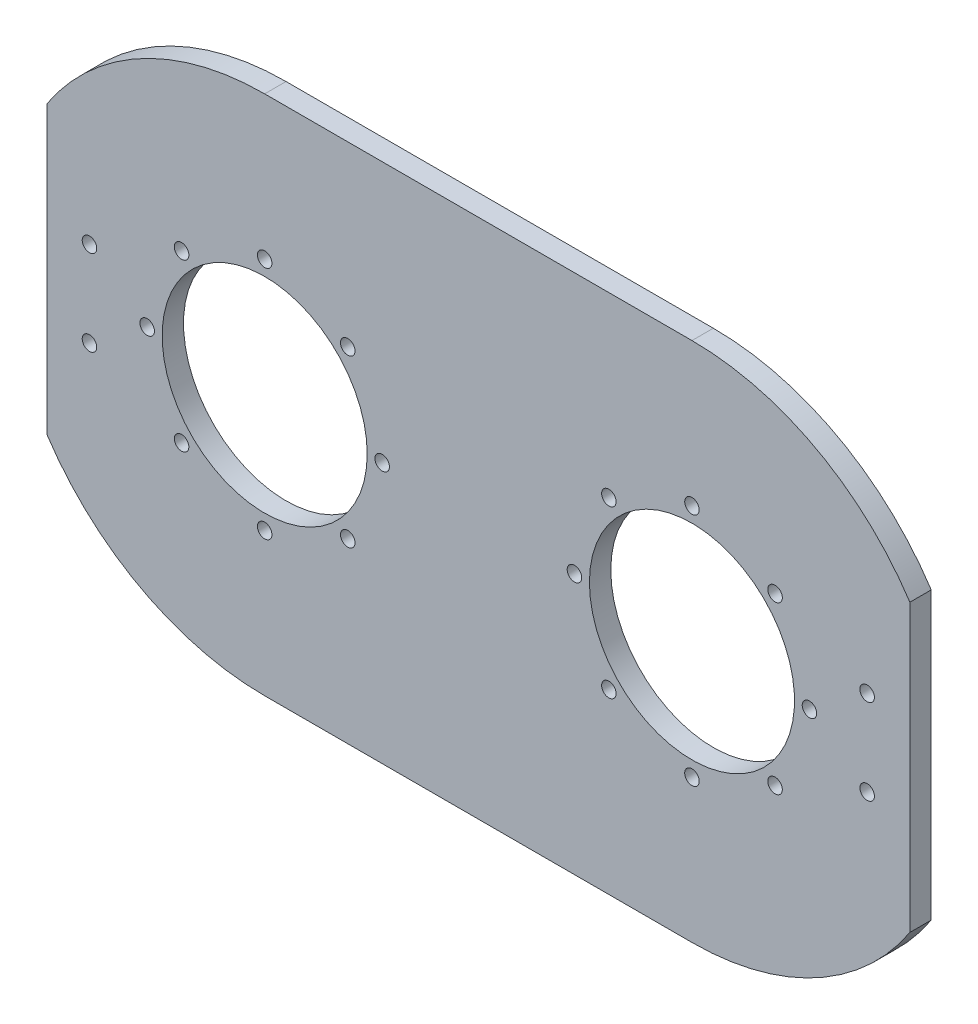
from build123d import *

# Parameters (mm, degrees)
EXTRUDE_1_DEPTH          = 5
SKETCH_2_R               = 24
CUT_EXTRUDE_1_DEPTH      = 6
HOLE_WIZARD_M3_1_D       = 3.4
PATTERN_CIRCULAR_1_COUNT = 8
MIRROR_1_COPY_1_D        = 3.4
MIRROR_1_COPY_2_D        = 3.4
MIRROR_1_COPY_3_D        = 3.4
MIRROR_1_COPY_4_D        = 3.4
MIRROR_1_COPY_5_D        = 3.4
MIRROR_1_COPY_6_D        = 3.4
MIRROR_1_COPY_7_D        = 3.4
CUT_EXTRUDE_2_DEPTH      = 6
HOLE_WIZARD_M3_2_D       = 3.4


with BuildPart() as part:
    # ｽｹｯﾁ1 → ﾎﾞｽ - 押し出し1 (new body)
    with BuildSketch(Plane.XY):
        with BuildLine():
            Line((-50, 61), (50, 61))
            ThreePointArc((50, 61), (111, 0), (50, -61))
            Line((50, -61), (-50, -61))
            ThreePointArc((-50, -61), (-111, 0), (-50, 61))
        make_face()
    extrude(amount=EXTRUDE_1_DEPTH)

    # ｽｹｯﾁ2 → ｶｯﾄ - 押し出し1 (cut, through all)
    with BuildSketch(Plane.XY.offset(5)):
        with Locations((-50, 0)):
            Circle(SKETCH_2_R)
    cut_extrude_1 = extrude(amount=-CUT_EXTRUDE_1_DEPTH, mode=Mode.SUBTRACT)

    # M3 すきま穴1 (through all)
    with Locations(Plane.XY.offset(5)):
        with Locations((-50, 27.5)):
            hole_wizard_m3_1 = Hole(HOLE_WIZARD_M3_1_D / 2)

    # 円形ﾊﾟﾀｰﾝ1: M3 すきま穴1 ×8 about axis
    pattern_circular_1_axis = Axis((-50, 0, 0), (0, 0, 1))
    for i in range(1, PATTERN_CIRCULAR_1_COUNT):
        add(hole_wizard_m3_1.rotate(pattern_circular_1_axis, i * 360 / PATTERN_CIRCULAR_1_COUNT), mode=Mode.SUBTRACT)

    # ﾐﾗｰ1: ｶｯﾄ - 押し出し1, M3 すきま穴1 across plane
    add(cut_extrude_1.mirror(Plane(origin=(0, 0, 0), x_dir=(0, 0, 1), z_dir=(1, 0, 0))), mode=Mode.SUBTRACT)
    add(hole_wizard_m3_1.mirror(Plane(origin=(0, 0, 0), x_dir=(0, 0, 1), z_dir=(1, 0, 0))), mode=Mode.SUBTRACT)

    # ﾐﾗｰ1 copy 1 (through all)
    with Locations(Plane(origin=(14.644660941, 35.355339059, 5), x_dir=(-0.707106781, 0.707106781, 0), z_dir=(0, 0, 1))):
        with Locations((-50, -27.5)):
            Hole(MIRROR_1_COPY_1_D / 2)

    # ﾐﾗｰ1 copy 2 (through all)
    with Locations(Plane(origin=(50, 50, 5), x_dir=(0, 1, 0), z_dir=(0, 0, 1))):
        with Locations((-50, -27.5)):
            Hole(MIRROR_1_COPY_2_D / 2)

    # ﾐﾗｰ1 copy 3 (through all)
    with Locations(Plane(origin=(85.355339059, 35.355339059, 5), x_dir=(0.707106781, 0.707106781, 0), z_dir=(0, 0, 1))):
        with Locations((-50, -27.5)):
            Hole(MIRROR_1_COPY_3_D / 2)

    # ﾐﾗｰ1 copy 4 (through all)
    with Locations(Plane(origin=(100, 0, 5), x_dir=(1, 0, 0), z_dir=(0, 0, 1))):
        with Locations((-50, -27.5)):
            Hole(MIRROR_1_COPY_4_D / 2)

    # ﾐﾗｰ1 copy 5 (through all)
    with Locations(Plane(origin=(85.355339059, -35.355339059, 5), x_dir=(0.707106781, -0.707106781, 0), z_dir=(0, 0, 1))):
        with Locations((-50, -27.5)):
            Hole(MIRROR_1_COPY_5_D / 2)

    # ﾐﾗｰ1 copy 6 (through all)
    with Locations(Plane(origin=(50, -50, 5), x_dir=(0, -1, 0), z_dir=(0, 0, 1))):
        with Locations((-50, -27.5)):
            Hole(MIRROR_1_COPY_6_D / 2)

    # ﾐﾗｰ1 copy 7 (through all)
    with Locations(Plane(origin=(14.644660941, -35.355339059, 5), x_dir=(-0.707106781, -0.707106781, 0), z_dir=(0, 0, 1))):
        with Locations((-50, -27.5)):
            Hole(MIRROR_1_COPY_7_D / 2)

    # ｽｹｯﾁ5 → ｶｯﾄ - 押し出し2 (cut, through all)
    with BuildSketch(Plane.XY.offset(5)):
        with BuildLine():
            Line((-101, 33.466401061), (-101, -33.466401061))
            ThreePointArc((-101, -33.466401061), (-111, 0), (-101, 33.466401061))
        make_face()
    cut_extrude_2 = extrude(amount=-CUT_EXTRUDE_2_DEPTH, mode=Mode.SUBTRACT)

    # M3 すきま穴2 (through all)
    with Locations(Plane.XY.offset(5)):
        with Locations((-91, 10), (-91, -10)):
            hole_wizard_m3_2 = Hole(HOLE_WIZARD_M3_2_D / 2)

    # ﾐﾗｰ2: ｶｯﾄ - 押し出し2, M3 すきま穴2 across plane
    add(cut_extrude_2.mirror(Plane(origin=(0, 0, 0), x_dir=(0, 0, 1), z_dir=(1, 0, 0))), mode=Mode.SUBTRACT)
    add(hole_wizard_m3_2.mirror(Plane(origin=(0, 0, 0), x_dir=(0, 0, 1), z_dir=(1, 0, 0))), mode=Mode.SUBTRACT)


solid = part.part
